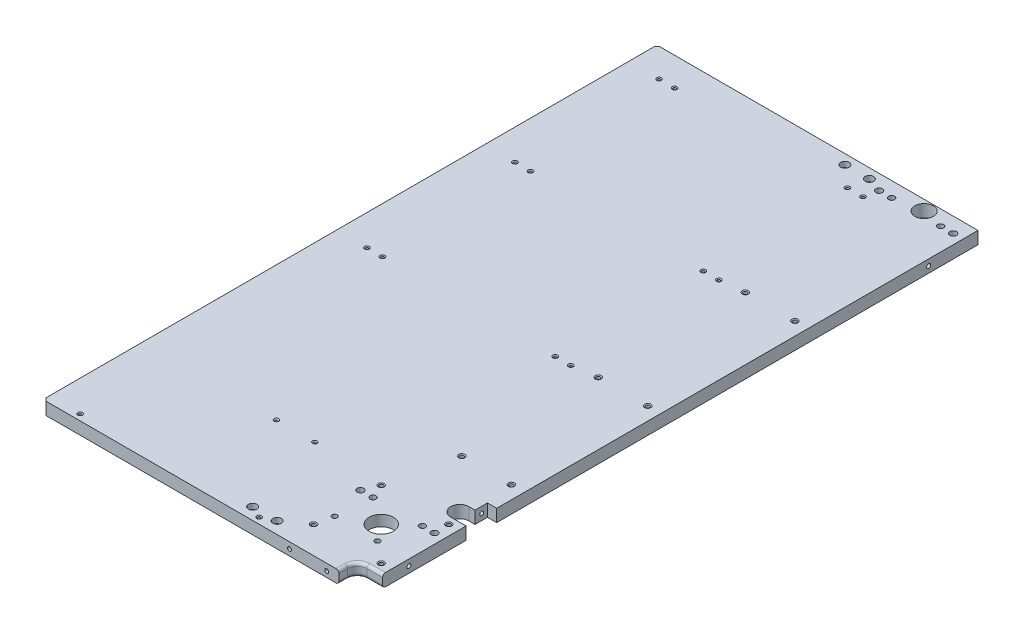
from build123d import *

# Parameters (mm, degrees)
SKETCH1_W              = 330.5
SKETCH1_H              = 632
BOSS_EXTRUDE1_DEPTH    = 12.8
CUT_EXTRUDE1_DEPTH     = 13.8
FILLET1_R              = 3
SKETCH3_R              = 1.45
CUT_EXTRUDE2_DEPTH     = 13.8
CHAMFER1_SIZE          = 1
CHAMFER1_SIZE2         = 0.577350269
CHAMFER1_PART_2_SIZE   = 1
CHAMFER1_PART_2_SIZE2  = 0.577350269
CHAMFER1_PART_3_SIZE   = 1
CHAMFER1_PART_3_SIZE2  = 0.577350269
CHAMFER1_PART_4_SIZE   = 1
CHAMFER1_PART_4_SIZE2  = 0.577350269
CHAMFER1_PART_5_SIZE   = 1
CHAMFER1_PART_5_SIZE2  = 0.577350269
CHAMFER1_PART_6_SIZE   = 1
CHAMFER1_PART_6_SIZE2  = 0.577350269
CHAMFER1_PART_7_SIZE   = 1
CHAMFER1_PART_7_SIZE2  = 0.577350269
CHAMFER1_PART_8_SIZE   = 1
CHAMFER1_PART_8_SIZE2  = 0.577350269
CHAMFER1_PART_9_SIZE   = 1
CHAMFER1_PART_9_SIZE2  = 0.577350269
CHAMFER1_PART_10_SIZE  = 1
CHAMFER1_PART_10_SIZE2 = 0.577350269
CHAMFER1_PART_11_SIZE  = 1
CHAMFER1_PART_11_SIZE2 = 0.577350269
CHAMFER1_PART_12_SIZE  = 1
CHAMFER1_PART_12_SIZE2 = 0.577350269
CHAMFER1_PART_13_SIZE  = 1
CHAMFER1_PART_13_SIZE2 = 0.577350269
CHAMFER1_PART_14_SIZE  = 1
CHAMFER1_PART_14_SIZE2 = 0.577350269
CHAMFER1_PART_15_SIZE  = 1
CHAMFER1_PART_15_SIZE2 = 0.577350269
SKETCH4_R              = 2.1
CUT_EXTRUDE3_DEPTH     = 13.8
CHAMFER2_SIZE          = 1
CHAMFER2_SIZE2         = 0.577350269
CHAMFER2_PART_2_SIZE   = 1
CHAMFER2_PART_2_SIZE2  = 0.577350269
CHAMFER2_PART_3_SIZE   = 1
CHAMFER2_PART_3_SIZE2  = 0.577350269
CHAMFER2_PART_4_SIZE   = 1
CHAMFER2_PART_4_SIZE2  = 0.577350269
CHAMFER2_PART_5_SIZE   = 1
CHAMFER2_PART_5_SIZE2  = 0.577350269
CHAMFER2_PART_6_SIZE   = 1
CHAMFER2_PART_6_SIZE2  = 0.577350269
CHAMFER2_PART_7_SIZE   = 1
CHAMFER2_PART_7_SIZE2  = 0.577350269
SKETCH5_R              = 12.5
SKETCH5_R_2            = 2.1
CUT_EXTRUDE4_DEPTH     = 13.8
SKETCH6_R              = 36.425
CUT_EXTRUDE5_DEPTH     = 1.7
CHAMFER3_SIZE          = 1
CHAMFER3_SIZE2         = 0.577350269
CHAMFER3_PART_2_SIZE   = 1
CHAMFER3_PART_2_SIZE2  = 0.577350269
CHAMFER3_PART_3_SIZE   = 1
CHAMFER3_PART_3_SIZE2  = 0.577350269
CHAMFER3_PART_4_SIZE   = 1
CHAMFER3_PART_4_SIZE2  = 0.577350269
CHAMFER3_PART_5_SIZE   = 1
CHAMFER3_PART_5_SIZE2  = 0.577350269
SKETCH7_R              = 2.7
SKETCH7_R_2            = 3.1
SKETCH7_R_3            = 3.425
CUT_EXTRUDE6_DEPTH     = 13.8
SKETCH13_R             = 4.4
CUT_EXTRUDE12_DEPTH    = 6.76
SKETCH8_R              = 9.51
CUT_EXTRUDE7_DEPTH     = 13.8
SKETCH9_R              = 2.6
CUT_EXTRUDE8_DEPTH     = 13.8
SKETCH10_R             = 4.365
CUT_EXTRUDE9_DEPTH     = 5.58
SKETCH11_R             = 3.425
SKETCH11_R_2           = 3.1
CUT_EXTRUDE10_DEPTH    = 13.8
SKETCH12_R             = 6.15
CUT_EXTRUDE11_DEPTH    = 7.82
SKETCH15_R             = 1.35
CUT_EXTRUDE13_DEPTH    = 13.8
CHAMFER4_SIZE          = 1
SKETCH16_R             = 2.025
CUT_EXTRUDE14_DEPTH    = 14.56
SKETCH17_R             = 2.03
SKETCH17_R_2           = 2.13
CUT_EXTRUDE15_DEPTH    = 15.24
SKETCH18_R             = 2.03
CUT_EXTRUDE17_DEPTH    = 15.24
CHAMFER5_SIZE          = 3
SKETCH19_R             = 1.475
CUT_EXTRUDE18_DEPTH    = 15.24
CHAMFER6_SIZE          = 1


with BuildPart() as part:
    # Sketch1 → Boss-Extrude1 (new body)
    with BuildSketch(Plane(origin=(0, 0, 0), x_dir=(1, 0, 0), z_dir=(0, 1, 0))):
        with Locations((165.25, 316)):
            Rectangle(SKETCH1_W, SKETCH1_H)
    extrude(amount=BOSS_EXTRUDE1_DEPTH)

    # Sketch2 → Cut-Extrude1 (cut, through all)
    with BuildSketch(Plane(origin=(0, 12.8, 0), x_dir=(-1, 0, 0), z_dir=(0, 1, 0))):
        with BuildLine():
            Line((-330.5, 0), (-304.5, 0))
            Line((-304.5, 0), (-304.5, -9))
            ThreePointArc((-304.5, -9), (-307.428932188, -16.071067812), (-314.5, -19))
            Line((-314.5, -19), (-330.5, -19))
            Line((-330.5, -19), (-330.5, 0))
        make_face()
        with BuildLine():
            Line((-330.5, -136.5), (-320.95, -136.5))
            Line((-320.95, -136.5), (-320.95, -123.7))
            Line((-320.95, -123.7), (-314.68, -123.7))
            ThreePointArc((-314.68, -123.7), (-305.33, -114.35), (-314.68, -105))
            Line((-314.68, -105), (-330.5, -105))
            Line((-330.5, -105), (-330.5, -136.5))
        make_face()
    extrude(amount=-CUT_EXTRUDE1_DEPTH, mode=Mode.SUBTRACT)

    # Fillet1
    fillet1_edges = [part.edges().sort_by_distance(p)[0] for p in [
        (304.5, 0, -4.5),
        (307.428932188, 0, -16.071067812),
        (322.5, 0, -19),
        (322.5, 12.8, -19),
        (307.428932188, 12.8, -16.071067812),
        (304.5, 12.8, -4.5),
    ]]
    fillet(fillet1_edges, radius=FILLET1_R)

    # Sketch3 → Cut-Extrude2 (cut, through all)
    with BuildSketch(Plane(origin=(0, 12.8, 0), x_dir=(-1, 0, 0), z_dir=(0, 1, 0))):
        with Locations((-31.8, -6.3)):
            Circle(SKETCH3_R)
        with Locations((-216.1, -6.3)):
            Circle(SKETCH3_R)
        with Locations((-31.4, -302)):
            Circle(SKETCH3_R)
        with Locations((-47.4, -302)):
            Circle(SKETCH3_R)
        with Locations((-31.4, -454.4)):
            Circle(SKETCH3_R)
        with Locations((-47.4, -454.4)):
            Circle(SKETCH3_R)
        with Locations((-31.4, -602.8)):
            Circle(SKETCH3_R)
        with Locations((-47.4, -602.8)):
            Circle(SKETCH3_R)
        with Locations((-225.3, -602.8)):
            Circle(SKETCH3_R)
        with Locations((-241.3, -602.8)):
            Circle(SKETCH3_R)
        with Locations((-225.3, -454.4)):
            Circle(SKETCH3_R)
        with Locations((-241.3, -454.4)):
            Circle(SKETCH3_R)
        with Locations((-241.3, -302)):
            Circle(SKETCH3_R)
        with Locations((-225.3, -302)):
            Circle(SKETCH3_R)
    extrude(amount=-CUT_EXTRUDE2_DEPTH, mode=Mode.SUBTRACT)

    # Chamfer1
    chamfer1_edges = [part.edges().sort_by_distance(p)[0] for p in [
        (48.85, 0, -454.4),
    ]]
    chamfer1_side = [part.faces().sort_by_distance(p)[0] for p in [
        (48.85, 6.4, -454.4),
    ]]
    chamfer(chamfer1_edges, length=CHAMFER1_SIZE, length2=CHAMFER1_SIZE2, reference=chamfer1_side[0])

    # Chamfer1 part 2
    chamfer1_part_2_edges = [part.edges().sort_by_distance(p)[0] for p in [
        (48.85, 12.8, -454.4),
        (32.85, 12.8, -602.8),
        (48.85, 12.8, -602.8),
        (226.75, 12.8, -602.8),
        (242.75, 12.8, -602.8),
        (226.75, 12.8, -454.4),
        (242.75, 12.8, -454.4),
        (242.75, 12.8, -302),
        (226.75, 12.8, -302),
        (33.25, 12.8, -6.3),
        (217.55, 12.8, -6.3),
        (32.85, 12.8, -302),
        (48.85, 12.8, -302),
        (32.85, 12.8, -454.4),
    ]]
    chamfer1_part_2_side = [part.faces().sort_by_distance(p)[0] for p in [
        (164.40986763, 12.8, -317.382866173),
    ]]
    chamfer(chamfer1_part_2_edges, length=CHAMFER1_PART_2_SIZE, length2=CHAMFER1_PART_2_SIZE2, reference=chamfer1_part_2_side[0])

    # Chamfer1 part 3
    chamfer1_part_3_edges = [part.edges().sort_by_distance(p)[0] for p in [
        (32.85, 0, -602.8),
    ]]
    chamfer1_part_3_side = [part.faces().sort_by_distance(p)[0] for p in [
        (32.85, 6.4, -602.8),
    ]]
    chamfer(chamfer1_part_3_edges, length=CHAMFER1_PART_3_SIZE, length2=CHAMFER1_PART_3_SIZE2, reference=chamfer1_part_3_side[0])

    # Chamfer1 part 4
    chamfer1_part_4_edges = [part.edges().sort_by_distance(p)[0] for p in [
        (48.85, 0, -602.8),
    ]]
    chamfer1_part_4_side = [part.faces().sort_by_distance(p)[0] for p in [
        (48.85, 6.4, -602.8),
    ]]
    chamfer(chamfer1_part_4_edges, length=CHAMFER1_PART_4_SIZE, length2=CHAMFER1_PART_4_SIZE2, reference=chamfer1_part_4_side[0])

    # Chamfer1 part 5
    chamfer1_part_5_edges = [part.edges().sort_by_distance(p)[0] for p in [
        (226.75, 0, -602.8),
    ]]
    chamfer1_part_5_side = [part.faces().sort_by_distance(p)[0] for p in [
        (226.75, 6.4, -602.8),
    ]]
    chamfer(chamfer1_part_5_edges, length=CHAMFER1_PART_5_SIZE, length2=CHAMFER1_PART_5_SIZE2, reference=chamfer1_part_5_side[0])

    # Chamfer1 part 6
    chamfer1_part_6_edges = [part.edges().sort_by_distance(p)[0] for p in [
        (242.75, 0, -602.8),
    ]]
    chamfer1_part_6_side = [part.faces().sort_by_distance(p)[0] for p in [
        (242.75, 6.4, -602.8),
    ]]
    chamfer(chamfer1_part_6_edges, length=CHAMFER1_PART_6_SIZE, length2=CHAMFER1_PART_6_SIZE2, reference=chamfer1_part_6_side[0])

    # Chamfer1 part 7
    chamfer1_part_7_edges = [part.edges().sort_by_distance(p)[0] for p in [
        (226.75, 0, -454.4),
    ]]
    chamfer1_part_7_side = [part.faces().sort_by_distance(p)[0] for p in [
        (226.75, 6.4, -454.4),
    ]]
    chamfer(chamfer1_part_7_edges, length=CHAMFER1_PART_7_SIZE, length2=CHAMFER1_PART_7_SIZE2, reference=chamfer1_part_7_side[0])

    # Chamfer1 part 8
    chamfer1_part_8_edges = [part.edges().sort_by_distance(p)[0] for p in [
        (242.75, 0, -454.4),
    ]]
    chamfer1_part_8_side = [part.faces().sort_by_distance(p)[0] for p in [
        (242.75, 6.4, -454.4),
    ]]
    chamfer(chamfer1_part_8_edges, length=CHAMFER1_PART_8_SIZE, length2=CHAMFER1_PART_8_SIZE2, reference=chamfer1_part_8_side[0])

    # Chamfer1 part 9
    chamfer1_part_9_edges = [part.edges().sort_by_distance(p)[0] for p in [
        (242.75, 0, -302),
    ]]
    chamfer1_part_9_side = [part.faces().sort_by_distance(p)[0] for p in [
        (242.75, 6.4, -302),
    ]]
    chamfer(chamfer1_part_9_edges, length=CHAMFER1_PART_9_SIZE, length2=CHAMFER1_PART_9_SIZE2, reference=chamfer1_part_9_side[0])

    # Chamfer1 part 10
    chamfer1_part_10_edges = [part.edges().sort_by_distance(p)[0] for p in [
        (226.75, 0, -302),
    ]]
    chamfer1_part_10_side = [part.faces().sort_by_distance(p)[0] for p in [
        (226.75, 6.4, -302),
    ]]
    chamfer(chamfer1_part_10_edges, length=CHAMFER1_PART_10_SIZE, length2=CHAMFER1_PART_10_SIZE2, reference=chamfer1_part_10_side[0])

    # Chamfer1 part 11
    chamfer1_part_11_edges = [part.edges().sort_by_distance(p)[0] for p in [
        (33.25, 0, -6.3),
    ]]
    chamfer1_part_11_side = [part.faces().sort_by_distance(p)[0] for p in [
        (33.25, 6.4, -6.3),
    ]]
    chamfer(chamfer1_part_11_edges, length=CHAMFER1_PART_11_SIZE, length2=CHAMFER1_PART_11_SIZE2, reference=chamfer1_part_11_side[0])

    # Chamfer1 part 12
    chamfer1_part_12_edges = [part.edges().sort_by_distance(p)[0] for p in [
        (217.55, 0, -6.3),
    ]]
    chamfer1_part_12_side = [part.faces().sort_by_distance(p)[0] for p in [
        (217.55, 6.4, -6.3),
    ]]
    chamfer(chamfer1_part_12_edges, length=CHAMFER1_PART_12_SIZE, length2=CHAMFER1_PART_12_SIZE2, reference=chamfer1_part_12_side[0])

    # Chamfer1 part 13
    chamfer1_part_13_edges = [part.edges().sort_by_distance(p)[0] for p in [
        (32.85, 0, -302),
    ]]
    chamfer1_part_13_side = [part.faces().sort_by_distance(p)[0] for p in [
        (32.85, 6.4, -302),
    ]]
    chamfer(chamfer1_part_13_edges, length=CHAMFER1_PART_13_SIZE, length2=CHAMFER1_PART_13_SIZE2, reference=chamfer1_part_13_side[0])

    # Chamfer1 part 14
    chamfer1_part_14_edges = [part.edges().sort_by_distance(p)[0] for p in [
        (48.85, 0, -302),
    ]]
    chamfer1_part_14_side = [part.faces().sort_by_distance(p)[0] for p in [
        (48.85, 6.4, -302),
    ]]
    chamfer(chamfer1_part_14_edges, length=CHAMFER1_PART_14_SIZE, length2=CHAMFER1_PART_14_SIZE2, reference=chamfer1_part_14_side[0])

    # Chamfer1 part 15
    chamfer1_part_15_edges = [part.edges().sort_by_distance(p)[0] for p in [
        (32.85, 0, -454.4),
    ]]
    chamfer1_part_15_side = [part.faces().sort_by_distance(p)[0] for p in [
        (32.85, 6.4, -454.4),
    ]]
    chamfer(chamfer1_part_15_edges, length=CHAMFER1_PART_15_SIZE, length2=CHAMFER1_PART_15_SIZE2, reference=chamfer1_part_15_side[0])

    # Sketch4 → Cut-Extrude3 (cut, through all)
    with BuildSketch(Plane(origin=(0, 12.8, 0), x_dir=(-1, 0, 0), z_dir=(0, 1, 0))):
        with Locations((-266, -457)):
            Circle(SKETCH4_R)
        with Locations((-317, -457)):
            Circle(SKETCH4_R)
        with Locations((-266, -305.5)):
            Circle(SKETCH4_R)
        with Locations((-317, -305.5)):
            Circle(SKETCH4_R)
        with Locations((-266, -165.1)):
            Circle(SKETCH4_R)
        with Locations((-317, -165.1)):
            Circle(SKETCH4_R)
    extrude(amount=-CUT_EXTRUDE3_DEPTH, mode=Mode.SUBTRACT)

    # Chamfer2
    chamfer2_edges = [part.edges().sort_by_distance(p)[0] for p in [
        (268.1, 0, -457),
    ]]
    chamfer2_side = [part.faces().sort_by_distance(p)[0] for p in [
        (268.1, 6.4, -457),
    ]]
    chamfer(chamfer2_edges, length=CHAMFER2_SIZE, length2=CHAMFER2_SIZE2, reference=chamfer2_side[0])

    # Chamfer2 part 2
    chamfer2_part_2_edges = [part.edges().sort_by_distance(p)[0] for p in [
        (268.1, 12.8, -457),
        (319.1, 12.8, -457),
        (268.1, 12.8, -305.5),
        (319.1, 12.8, -305.5),
        (268.1, 12.8, -165.1),
        (319.1, 12.8, -165.1),
    ]]
    chamfer2_part_2_side = [part.faces().sort_by_distance(p)[0] for p in [
        (164.383598032, 12.8, -317.326706159),
    ]]
    chamfer(chamfer2_part_2_edges, length=CHAMFER2_PART_2_SIZE, length2=CHAMFER2_PART_2_SIZE2, reference=chamfer2_part_2_side[0])

    # Chamfer2 part 3
    chamfer2_part_3_edges = [part.edges().sort_by_distance(p)[0] for p in [
        (319.1, 0, -457),
    ]]
    chamfer2_part_3_side = [part.faces().sort_by_distance(p)[0] for p in [
        (319.1, 6.4, -457),
    ]]
    chamfer(chamfer2_part_3_edges, length=CHAMFER2_PART_3_SIZE, length2=CHAMFER2_PART_3_SIZE2, reference=chamfer2_part_3_side[0])

    # Chamfer2 part 4
    chamfer2_part_4_edges = [part.edges().sort_by_distance(p)[0] for p in [
        (268.1, 0, -305.5),
    ]]
    chamfer2_part_4_side = [part.faces().sort_by_distance(p)[0] for p in [
        (268.1, 6.4, -305.5),
    ]]
    chamfer(chamfer2_part_4_edges, length=CHAMFER2_PART_4_SIZE, length2=CHAMFER2_PART_4_SIZE2, reference=chamfer2_part_4_side[0])

    # Chamfer2 part 5
    chamfer2_part_5_edges = [part.edges().sort_by_distance(p)[0] for p in [
        (319.1, 0, -305.5),
    ]]
    chamfer2_part_5_side = [part.faces().sort_by_distance(p)[0] for p in [
        (319.1, 6.4, -305.5),
    ]]
    chamfer(chamfer2_part_5_edges, length=CHAMFER2_PART_5_SIZE, length2=CHAMFER2_PART_5_SIZE2, reference=chamfer2_part_5_side[0])

    # Chamfer2 part 6
    chamfer2_part_6_edges = [part.edges().sort_by_distance(p)[0] for p in [
        (268.1, 0, -165.1),
    ]]
    chamfer2_part_6_side = [part.faces().sort_by_distance(p)[0] for p in [
        (268.1, 6.4, -165.1),
    ]]
    chamfer(chamfer2_part_6_edges, length=CHAMFER2_PART_6_SIZE, length2=CHAMFER2_PART_6_SIZE2, reference=chamfer2_part_6_side[0])

    # Chamfer2 part 7
    chamfer2_part_7_edges = [part.edges().sort_by_distance(p)[0] for p in [
        (319.1, 0, -165.1),
    ]]
    chamfer2_part_7_side = [part.faces().sort_by_distance(p)[0] for p in [
        (319.1, 6.4, -165.1),
    ]]
    chamfer(chamfer2_part_7_edges, length=CHAMFER2_PART_7_SIZE, length2=CHAMFER2_PART_7_SIZE2, reference=chamfer2_part_7_side[0])

    # Sketch5 → Cut-Extrude4 (cut, through all)
    with BuildSketch(Plane(origin=(0, 12.8, 0), x_dir=(1, 0, 0), z_dir=(0, 1, 0))):
        with Locations((285.3, 62.8)):
            Circle(SKETCH5_R)
        with Locations((320.1, 97.6)):
            Circle(SKETCH5_R_2)
        with Locations((320.1, 28)):
            Circle(SKETCH5_R_2)
        with Locations((250.5, 28)):
            Circle(SKETCH5_R_2)
        with Locations((250.5, 97.6)):
            Circle(SKETCH5_R_2)
    extrude(amount=-CUT_EXTRUDE4_DEPTH, mode=Mode.SUBTRACT)

    # Sketch6 → Cut-Extrude5 (cut)
    with BuildSketch(Plane.XZ):
        with Locations((285.3, -62.8)):
            Circle(SKETCH6_R)
    extrude(amount=-CUT_EXTRUDE5_DEPTH, mode=Mode.SUBTRACT)

    # Chamfer3
    chamfer3_edges = [part.edges().sort_by_distance(p)[0] for p in [
        (318, 0, -97.6),
    ]]
    chamfer3_side = [part.faces().sort_by_distance(p)[0] for p in [
        (318, 6.4, -97.6),
    ]]
    chamfer(chamfer3_edges, length=CHAMFER3_SIZE, length2=CHAMFER3_SIZE2, reference=chamfer3_side[0])

    # Chamfer3 part 2
    chamfer3_part_2_edges = [part.edges().sort_by_distance(p)[0] for p in [
        (318, 12.8, -97.6),
        (318, 12.8, -28),
        (248.4, 12.8, -28),
        (248.4, 12.8, -97.6),
    ]]
    chamfer3_part_2_side = [part.faces().sort_by_distance(p)[0] for p in [
        (164.003797132, 12.8, -318.003163792),
    ]]
    chamfer(chamfer3_part_2_edges, length=CHAMFER3_PART_2_SIZE, length2=CHAMFER3_PART_2_SIZE2, reference=chamfer3_part_2_side[0])

    # Chamfer3 part 3
    chamfer3_part_3_edges = [part.edges().sort_by_distance(p)[0] for p in [
        (318, 0, -28),
    ]]
    chamfer3_part_3_side = [part.faces().sort_by_distance(p)[0] for p in [
        (318, 6.4, -28),
    ]]
    chamfer(chamfer3_part_3_edges, length=CHAMFER3_PART_3_SIZE, length2=CHAMFER3_PART_3_SIZE2, reference=chamfer3_part_3_side[0])

    # Chamfer3 part 4
    chamfer3_part_4_edges = [part.edges().sort_by_distance(p)[0] for p in [
        (248.4, 0, -28),
    ]]
    chamfer3_part_4_side = [part.faces().sort_by_distance(p)[0] for p in [
        (248.4, 6.4, -28),
    ]]
    chamfer(chamfer3_part_4_edges, length=CHAMFER3_PART_4_SIZE, length2=CHAMFER3_PART_4_SIZE2, reference=chamfer3_part_4_side[0])

    # Chamfer3 part 5
    chamfer3_part_5_edges = [part.edges().sort_by_distance(p)[0] for p in [
        (248.4, 0, -97.6),
    ]]
    chamfer3_part_5_side = [part.faces().sort_by_distance(p)[0] for p in [
        (248.4, 6.4, -97.6),
    ]]
    chamfer(chamfer3_part_5_edges, length=CHAMFER3_PART_5_SIZE, length2=CHAMFER3_PART_5_SIZE2, reference=chamfer3_part_5_side[0])

    # Sketch7 → Cut-Extrude6 (cut, through all)
    with BuildSketch(Plane(origin=(0, 12.8, 0), x_dir=(1, 0, 0), z_dir=(0, 1, 0))):
        with Locations((254.2, 45.9)):
            Circle(SKETCH7_R)
        with Locations((298.4, 45.9)):
            Circle(SKETCH7_R)
        with Locations((308, 82.5)):
            Circle(SKETCH7_R_2)
        with Locations((257.2, 82.5)):
            Circle(SKETCH7_R_2)
        with Locations((320.5, 82.5)):
            Circle(SKETCH7_R_3)
        with Locations((244.2, 82.5)):
            Circle(SKETCH7_R_3)
    extrude(amount=-CUT_EXTRUDE6_DEPTH, mode=Mode.SUBTRACT)

    # Sketch13 → Cut-Extrude12 (cut)
    with BuildSketch(Plane.XZ):
        with Locations((254.2, -45.9)):
            Circle(SKETCH13_R)
        with Locations((298.4, -45.9)):
            Circle(SKETCH13_R)
    extrude(amount=-CUT_EXTRUDE12_DEPTH, mode=Mode.SUBTRACT)

    # Sketch8 → Cut-Extrude7 (cut, through all)
    with BuildSketch(Plane(origin=(0, 12.8, 0), x_dir=(1, 0, 0), z_dir=(0, 1, 0))):
        with Locations((285.51, 621.5)):
            Circle(SKETCH8_R)
    extrude(amount=-CUT_EXTRUDE7_DEPTH, mode=Mode.SUBTRACT)

    # Sketch9 → Cut-Extrude8 (cut, through all)
    with BuildSketch(Plane(origin=(0, 12.8, 0), x_dir=(-1, 0, 0), z_dir=(0, 1, 0))):
        with Locations((-228.7, -622)):
            Circle(SKETCH9_R)
        with Locations((-203.5, -622)):
            Circle(SKETCH9_R)
        with Locations((-203.5, -12.25)):
            Circle(SKETCH9_R)
        with Locations((-228.7, -12.25)):
            Circle(SKETCH9_R)
    extrude(amount=-CUT_EXTRUDE8_DEPTH, mode=Mode.SUBTRACT)

    # Sketch10 → Cut-Extrude9 (cut)
    with BuildSketch(Plane(origin=(0, 12.8, 0), x_dir=(-1, 0, 0), z_dir=(0, 1, 0))):
        with Locations((-203.5, -622)):
            Circle(SKETCH10_R)
        with Locations((-228.7, -622)):
            Circle(SKETCH10_R)
        with Locations((-203.5, -12.25)):
            Circle(SKETCH10_R)
        with Locations((-228.7, -12.25)):
            Circle(SKETCH10_R)
    extrude(amount=-CUT_EXTRUDE9_DEPTH, mode=Mode.SUBTRACT)

    # Sketch11 → Cut-Extrude10 (cut, through all)
    with BuildSketch(Plane(origin=(0, 12.8, 0), x_dir=(-1, 0, 0), z_dir=(0, 1, 0))):
        with Locations((-244.2, -616.5)):
            Circle(SKETCH11_R)
        with Locations((-257, -616.5)):
            Circle(SKETCH11_R_2)
        with Locations((-307.5, -616.5)):
            Circle(SKETCH11_R_2)
        with Locations((-320.5, -616.5)):
            Circle(SKETCH11_R)
    extrude(amount=-CUT_EXTRUDE10_DEPTH, mode=Mode.SUBTRACT)

    # Sketch12 → Cut-Extrude11 (cut)
    with BuildSketch(Plane.XZ):
        with Locations((244.2, -616.5)):
            Circle(SKETCH12_R)
        with Locations((320.5, -616.5)):
            Circle(SKETCH12_R)
        with Locations((320.5, -82.5)):
            Circle(SKETCH12_R)
        with Locations((244.2, -82.5)):
            Circle(SKETCH12_R)
    extrude(amount=-CUT_EXTRUDE11_DEPTH, mode=Mode.SUBTRACT)

    # Sketch15 → Cut-Extrude13 (cut, through all)
    with BuildSketch(Plane(origin=(0, 12.8, 0), x_dir=(1, 0, 0), z_dir=(0, 1, 0))):
        with Locations((138.3, 101.9)):
            Circle(SKETCH15_R)
        with Locations((177.9, 101.9)):
            Circle(SKETCH15_R)
    extrude(amount=-CUT_EXTRUDE13_DEPTH, mode=Mode.SUBTRACT)

    # Chamfer4
    chamfer4_edges = [part.edges().sort_by_distance(p)[0] for p in [
        (136.95, 0, -101.9),
        (136.95, 12.8, -101.9),
        (176.55, 0, -101.9),
        (176.55, 12.8, -101.9),
    ]]
    chamfer(chamfer4_edges, length=CHAMFER4_SIZE)

    # Sketch16 → Cut-Extrude14 (cut)
    with BuildSketch(Plane.XY):
        with Locations((253.7, 6.4)):
            Circle(SKETCH16_R)
        with Locations((292, 5.8)):
            Circle(SKETCH16_R)
    extrude(amount=-CUT_EXTRUDE14_DEPTH, mode=Mode.SUBTRACT)

    # Sketch17 → Cut-Extrude15 (cut)
    with BuildSketch(Plane(origin=(330.5, 0, 0), x_dir=(0, 0, -1), z_dir=(1, 0, 0))):
        with Locations((46.12, 6.4)):
            Circle(SKETCH17_R)
        with Locations((581.2, 6.4)):
            Circle(SKETCH17_R_2)
    extrude(amount=-CUT_EXTRUDE15_DEPTH, mode=Mode.SUBTRACT)

    # Sketch18 → Cut-Extrude17 (cut)
    with BuildSketch(Plane(origin=(320.95, 0, 0), x_dir=(0, 0, -1), z_dir=(1, 0, 0))):
        with Locations((130.62, 6.4)):
            Circle(SKETCH18_R)
    extrude(amount=-CUT_EXTRUDE17_DEPTH, mode=Mode.SUBTRACT)

    # Chamfer5
    chamfer5_edges = [part.edges().sort_by_distance(p)[0] for p in [
        (0, 6.4, -632),
        (0, 6.4, 0),
    ]]
    chamfer(chamfer5_edges, length=CHAMFER5_SIZE)

    # Sketch19 → Cut-Extrude18 (cut)
    with BuildSketch(Plane(origin=(0, 0, -632), x_dir=(-1, 0, 0), z_dir=(0, 0, -1))):
        with Locations((-215.95, 6.4)):
            Circle(SKETCH19_R)
        with Locations((-38.1, 6.4)):
            Circle(SKETCH19_R)
    extrude(amount=-CUT_EXTRUDE18_DEPTH, mode=Mode.SUBTRACT)

    # Chamfer6
    chamfer6_edges = [part.edges().sort_by_distance(p)[0] for p in [
        (217.425, 6.4, -632),
        (39.575, 6.4, -632),
    ]]
    chamfer(chamfer6_edges, length=CHAMFER6_SIZE)


solid = part.part
